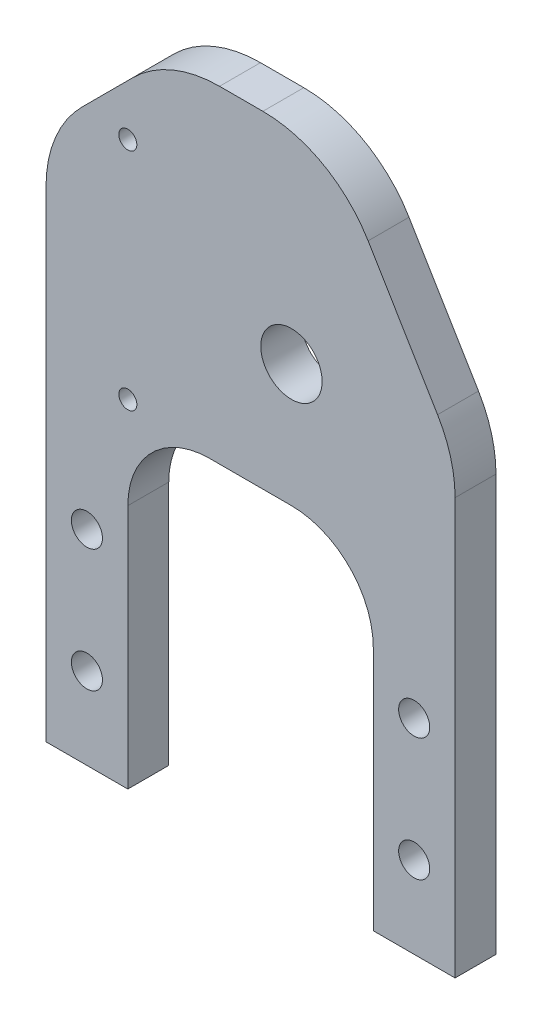
from build123d import *

# Parameters (mm, degrees)
BOSS_EXTRUDE1_DEPTH = 6.35
CUT_EXTRUDE1_REACH  = 8.35
SKETCH2_R           = 2.413
CUT_EXTRUDE3_REACH  = 8.35
SKETCH4_R           = 1.397
SKETCH4_R_2         = 4.7625
FILLET4_R           = 12.7
FILLET5_R           = 19.05


with BuildPart() as part:
    # Sketch1 → Boss-Extrude1 (new body)
    with BuildSketch(Plane.XY):
        Polygon((0, 0), (12.7, 0), (12.7, 50.8), (50.8, 50.8), (50.8, 0), (63.5, 0), (63.5, 69.85), (44.45, 101.6), (19.05, 101.6), (0, 82.55), align=None)
    extrude(amount=BOSS_EXTRUDE1_DEPTH)

    # Sketch2 → Cut-Extrude1 (cut, up to next)
    with BuildSketch(Plane.XY.offset(6.35), mode=Mode.PRIVATE) as cut_extrude1_sk1:
        with Locations((6.35, 12.7)):
            Circle(SKETCH2_R)
    cut_extrude1_tool1 = extrude(cut_extrude1_sk1.sketch, amount=-CUT_EXTRUDE1_REACH, mode=Mode.PRIVATE) & part.part
    add(cut_extrude1_tool1.solids().sort_by_distance((6.35, 12.7, 6.35))[0], mode=Mode.SUBTRACT)
    # Sketch2 → Cut-Extrude1 (cut, up to next)
    with BuildSketch(Plane.XY.offset(6.35), mode=Mode.PRIVATE) as cut_extrude1_sk2:
        with Locations((6.35, 31.75)):
            Circle(SKETCH2_R)
    cut_extrude1_tool2 = extrude(cut_extrude1_sk2.sketch, amount=-CUT_EXTRUDE1_REACH, mode=Mode.PRIVATE) & part.part
    add(cut_extrude1_tool2.solids().sort_by_distance((6.35, 31.75, 6.35))[0], mode=Mode.SUBTRACT)
    # Sketch2 → Cut-Extrude1 (cut, up to next)
    with BuildSketch(Plane.XY.offset(6.35), mode=Mode.PRIVATE) as cut_extrude1_sk3:
        with Locations((57.15, 12.7)):
            Circle(SKETCH2_R)
    cut_extrude1_tool3 = extrude(cut_extrude1_sk3.sketch, amount=-CUT_EXTRUDE1_REACH, mode=Mode.PRIVATE) & part.part
    add(cut_extrude1_tool3.solids().sort_by_distance((57.15, 12.7, 6.35))[0], mode=Mode.SUBTRACT)
    # Sketch2 → Cut-Extrude1 (cut, up to next)
    with BuildSketch(Plane.XY.offset(6.35), mode=Mode.PRIVATE) as cut_extrude1_sk4:
        with Locations((57.15, 31.75)):
            Circle(SKETCH2_R)
    cut_extrude1_tool4 = extrude(cut_extrude1_sk4.sketch, amount=-CUT_EXTRUDE1_REACH, mode=Mode.PRIVATE) & part.part
    add(cut_extrude1_tool4.solids().sort_by_distance((57.15, 31.75, 6.35))[0], mode=Mode.SUBTRACT)

    # Sketch4 → Cut-Extrude3 (cut, up to next)
    with BuildSketch(Plane.XY.offset(6.35), mode=Mode.PRIVATE) as cut_extrude3_sk1:
        with Locations((12.7, 52.3875)):
            Circle(SKETCH4_R)
    cut_extrude3_tool1 = extrude(cut_extrude3_sk1.sketch, amount=-CUT_EXTRUDE3_REACH, mode=Mode.PRIVATE) & part.part
    add(cut_extrude3_tool1.solids().sort_by_distance((12.7, 52.3875, 6.35))[0], mode=Mode.SUBTRACT)
    # Sketch4 → Cut-Extrude3 (cut, up to next)
    with BuildSketch(Plane.XY.offset(6.35), mode=Mode.PRIVATE) as cut_extrude3_sk2:
        with Locations((12.7, 87.3125)):
            Circle(SKETCH4_R)
    cut_extrude3_tool2 = extrude(cut_extrude3_sk2.sketch, amount=-CUT_EXTRUDE3_REACH, mode=Mode.PRIVATE) & part.part
    add(cut_extrude3_tool2.solids().sort_by_distance((12.7, 87.3125, 6.35))[0], mode=Mode.SUBTRACT)
    # Sketch4 → Cut-Extrude3 (cut, up to next)
    with BuildSketch(Plane.XY.offset(6.35), mode=Mode.PRIVATE) as cut_extrude3_sk3:
        with Locations((38.1, 69.85)):
            Circle(SKETCH4_R_2)
    cut_extrude3_tool3 = extrude(cut_extrude3_sk3.sketch, amount=-CUT_EXTRUDE3_REACH, mode=Mode.PRIVATE) & part.part
    add(cut_extrude3_tool3.solids().sort_by_distance((38.1, 69.85, 6.35))[0], mode=Mode.SUBTRACT)

    # Fillet4
    fillet4_edges = [part.edges().sort_by_distance(p)[0] for p in [
        (50.8, 50.8, 3.175),
        (12.7, 50.8, 3.175),
    ]]
    fillet(fillet4_edges, radius=FILLET4_R)

    # Fillet5
    fillet5_edges = [part.edges().sort_by_distance(p)[0] for p in [
        (0, 82.55, 3.175),
        (19.05, 101.6, 3.175),
        (44.45, 101.6, 3.175),
        (63.5, 69.85, 3.175),
    ]]
    fillet(fillet5_edges, radius=FILLET5_R)


solid = part.part
